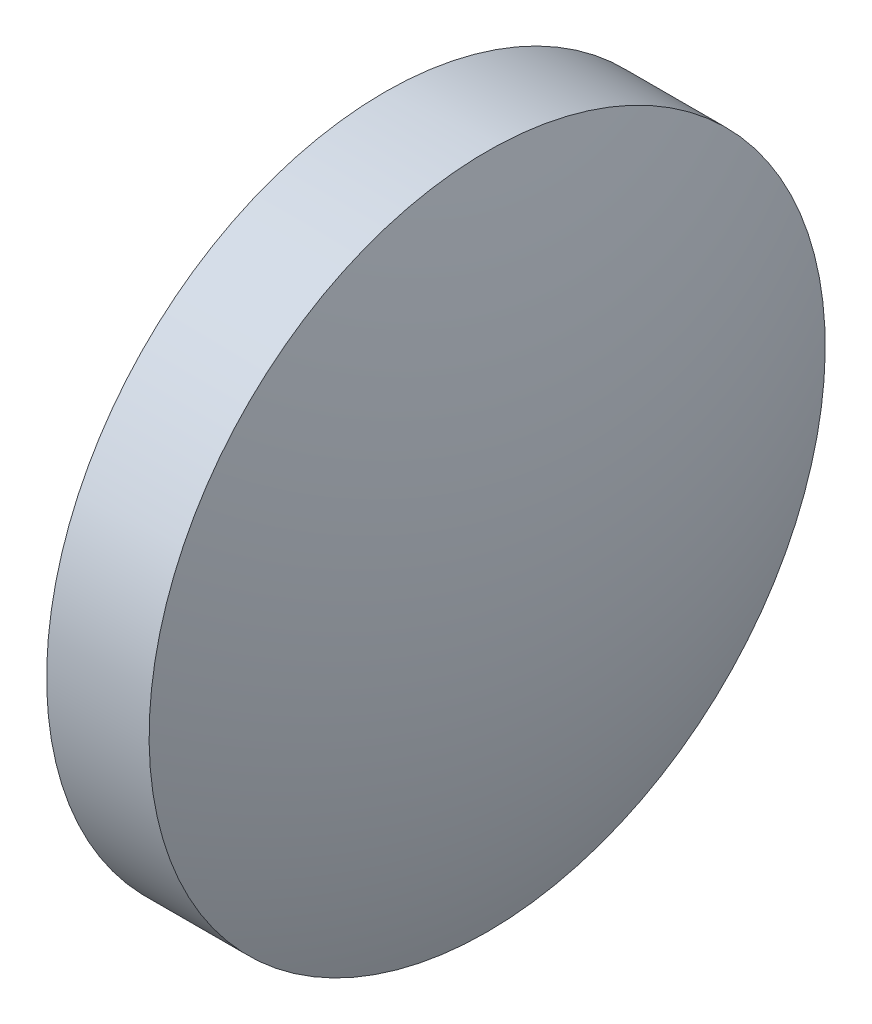
from build123d import *

# Parameters (mm, degrees)
SKETCH_1_ONE_SIDE_W = 1.97
SKETCH_1_ONE_SIDE_H = 6.500018572


with BuildPart() as part:
    # 草图1 one side → 旋转1 (revolve)
    with BuildSketch(Plane.XY, mode=Mode.PRIVATE) as revolve_1_sk:
        with Locations((44.250383086, 28.132342949)):
            Rectangle(SKETCH_1_ONE_SIDE_W, SKETCH_1_ONE_SIDE_H)
        with BuildLine():
            Line((42.050383086, 24.882333663), (43.265383086, 24.882333663))
            Line((43.265383086, 24.882333663), (43.265383086, 31.382352235))
            ThreePointArc((43.265383086, 31.382352235), (42.356740981, 28.188633197), (42.050383086, 24.882333663))
        make_face()
        with BuildLine():
            Line((45.235383086, 24.882333663), (46.450383086, 24.882333663))
            ThreePointArc((46.450383086, 24.882333663), (46.144025191, 28.188633197), (45.235383086, 31.382352235))
            Line((45.235383086, 31.382352235), (45.235383086, 24.882333663))
        make_face()
    revolve(revolve_1_sk.sketch.rotate(Axis((40.9599614, 24.882333663, 0), (1, 0, 0)), 180), axis=Axis((40.9599614, 24.882333663, 0), (1, 0, 0)))  # turned: the seam where the file's is


solid = part.part
